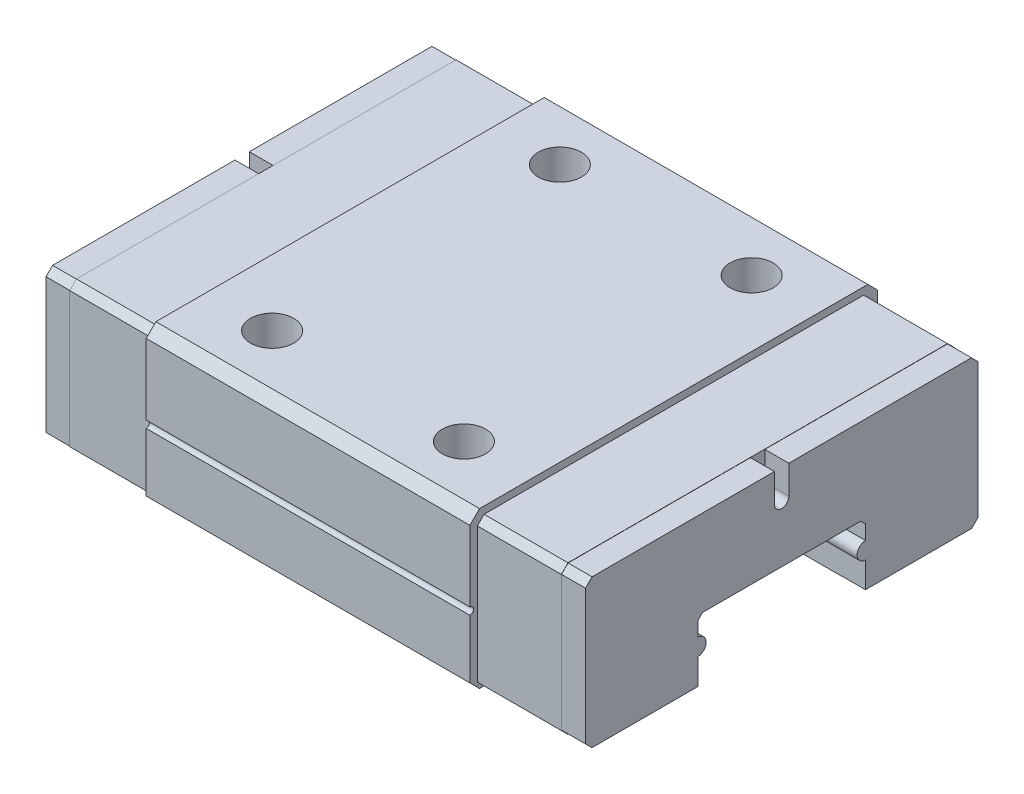
from build123d import *

# Parameters (mm, degrees)
EXTRUDE_1_DEPTH      = 13.5
SKETCH_3_R           = 0.15
CUT_EXTRUDE_2_DEPTH  = 13.5
EXTRUDE_2_DEPTH      = 3.5
EXTRUDE_2_DEPTH_BACK = 17
EXTRUDE_3_DEPTH      = 1
EXTRUDE_3_DEPTH_BACK = 21.5
SKETCH_2_R           = 0.9
CUT_EXTRUDE_1_DEPTH  = 2.5
CUT_EXTRUDE_3_DEPTH  = 1
CUT_EXTRUDE_4_DEPTH  = 1
SKETCH_8_R           = 0.3
CUT_EXTRUDE_5_DEPTH  = 4.5
SKETCH_9_R           = 0.3
CUT_EXTRUDE_6_DEPTH  = 4.5
CUT_EXTRUDE_7_DEPTH  = 22.5


with BuildPart() as part:
    # 草图1 → 凸台-拉伸1 (new body)
    with BuildSketch(Plane(origin=(0, 0, 0), x_dir=(0, 0, -1), z_dir=(1, 0, 0))):
        Polygon((-8.5, 2.846949135), (-8.096949135, 3.25), (8.096949135, 3.25), (8.5, 2.846949135), (8.5, -2.846949135), (8.096949135, -3.25), (-8.096949135, -3.25), (-8.5, -2.846949135), align=None)
    extrude(amount=EXTRUDE_1_DEPTH)

    # 草图3 → 切除-拉伸2 (cut)
    with BuildSketch(Plane.ZY):
        with Locations((8.5, -0.253050865)):
            Circle(SKETCH_3_R)
        with Locations((-8.5, -0.253050865)):
            Circle(SKETCH_3_R)
    extrude(amount=-CUT_EXTRUDE_2_DEPTH, mode=Mode.SUBTRACT)

    # 草图4 → 凸台-拉伸2 (add, two sides)
    with BuildSketch(Plane.ZY) as extrude_2_sk:
        Polygon((8.19, -2.970178628), (8.19, 2.67), (7.91, 2.95), (-7.92, 2.95), (-8.2, 2.67), (-8.2, -2.970178628), (-7.930178628, -3.24), (7.920178628, -3.24), align=None)
    extrude(amount=EXTRUDE_2_DEPTH)
    extrude(extrude_2_sk.sketch, amount=-EXTRUDE_2_DEPTH_BACK)

    # 草图5 → 凸台-拉伸3 (add, two sides)
    with BuildSketch(Plane(origin=(17, 0, 0), x_dir=(0, 0, -1), z_dir=(1, 0, 0))) as extrude_3_sk:
        Polygon((-7.905857864, 2.94), (7.915857864, 2.94), (8.19, 2.665857864), (8.19, -2.966036493), (7.926036493, -3.23), (-7.910178628, -3.23), (-8.18, -2.960178628), (-8.18, 2.665857864), align=None)
    extrude(amount=EXTRUDE_3_DEPTH)
    extrude(extrude_3_sk.sketch, amount=-EXTRUDE_3_DEPTH_BACK)

    # 草图2 → 切除-拉伸1 (cut)
    with BuildSketch(Plane(origin=(0, 3.25, 0), x_dir=(1, 0, 0), z_dir=(0, 1, 0))):
        with Locations((2.75, 6)):
            Circle(SKETCH_2_R)
        with Locations((10.75, 6)):
            Circle(SKETCH_2_R)
        with Locations((10.75, -6)):
            Circle(SKETCH_2_R)
        with Locations((2.75, -6)):
            Circle(SKETCH_2_R)
    extrude(amount=-CUT_EXTRUDE_1_DEPTH, mode=Mode.SUBTRACT)

    # 草图6 → 切除-拉伸3 (cut)
    with BuildSketch(Plane(origin=(18, 0, 0), x_dir=(0, 0, -1), z_dir=(1, 0, 0))):
        with BuildLine():
            Line((0.3, 1.75), (0.3, 2.94))
            Line((0.3, 2.94), (-0.3, 2.94))
            Line((-0.3, 2.94), (-0.3, 1.75))
            ThreePointArc((-0.3, 1.75), (0, 1.45), (0.3, 1.75))
        make_face()
    extrude(amount=-CUT_EXTRUDE_3_DEPTH, mode=Mode.SUBTRACT)

    # 草图7 → 切除-拉伸4 (cut)
    with BuildSketch(Plane.ZY.offset(4.5)):
        with BuildLine():
            Line((-0.3, 1.75), (-0.3, 2.94))
            Line((-0.3, 2.94), (0.3, 2.94))
            Line((0.3, 2.94), (0.3, 1.75))
            ThreePointArc((0.3, 1.75), (0, 1.45), (-0.3, 1.75))
        make_face()
    extrude(amount=-CUT_EXTRUDE_4_DEPTH, mode=Mode.SUBTRACT)

    # 草图8 → 切除-拉伸5 (cut)
    with BuildSketch(Plane.ZY.offset(4.5)):
        with Locations((0, 1.75)):
            Circle(SKETCH_8_R)
    extrude(amount=-CUT_EXTRUDE_5_DEPTH, mode=Mode.SUBTRACT)

    # 草图9 → 切除-拉伸6 (cut)
    with BuildSketch(Plane(origin=(18, 0, 0), x_dir=(0, 0, -1), z_dir=(1, 0, 0))):
        with Locations((0, 1.75)):
            Circle(SKETCH_9_R)
    extrude(amount=-CUT_EXTRUDE_6_DEPTH, mode=Mode.SUBTRACT)

    # 草图10 → 切除-拉伸7 (cut)
    with BuildSketch(Plane(origin=(18, 0, 0), x_dir=(0, 0, -1), z_dir=(1, 0, 0))):
        with BuildLine():
            Line((3.497989899, -2.15), (3.497989899, -3.25))
            Line((3.497989899, -3.25), (-3.497989899, -3.25))
            Line((-3.497989899, -3.25), (-3.497989899, -2.15))
            ThreePointArc((-3.497989899, -2.15), (-3.147989899, -1.8), (-3.497989899, -1.45))
            Line((-3.497989899, -1.45), (-3.497989899, -0.85))
            Line((-3.497989899, -0.85), (-3.3, -0.652010101))
            Line((-3.3, -0.652010101), (3.3, -0.652010101))
            Line((3.3, -0.652010101), (3.497989899, -0.85))
            Line((3.497989899, -0.85), (3.497989899, -1.45))
            ThreePointArc((3.497989899, -1.45), (3.147989899, -1.8), (3.497989899, -2.15))
        make_face()
    extrude(amount=-CUT_EXTRUDE_7_DEPTH, mode=Mode.SUBTRACT)


solid = part.part
